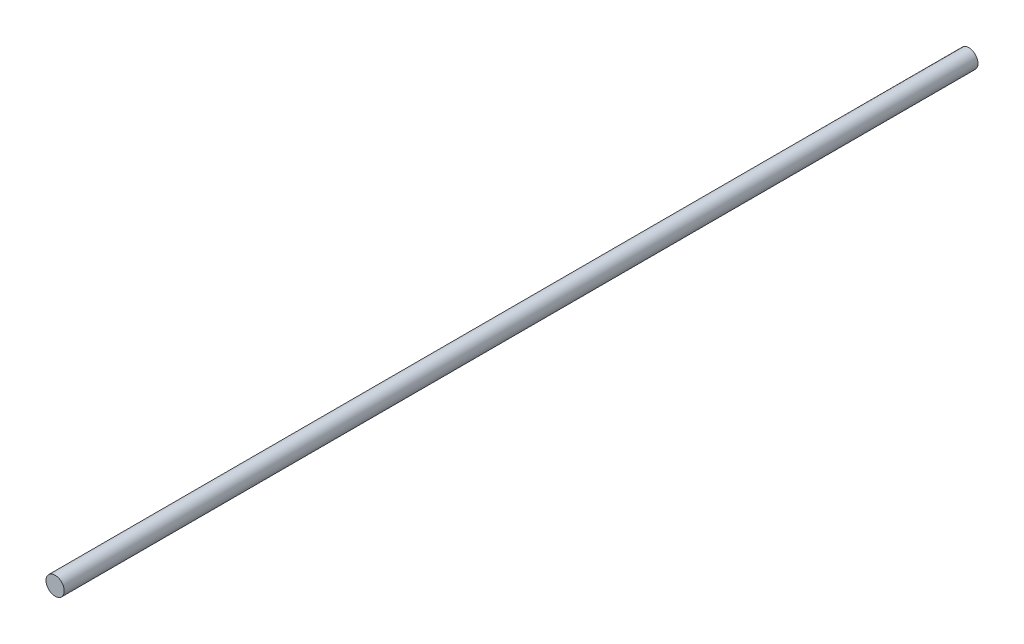
from build123d import *

# Parameters (mm, degrees)
ESQUISSE1_R        = 5
BOSS_EXTRU_1_DEPTH = 500


with BuildPart() as part:
    # Esquisse1 → Boss.-Extru.1 (new body)
    with BuildSketch(Plane.XY):
        Circle(ESQUISSE1_R)
    extrude(amount=BOSS_EXTRU_1_DEPTH)


solid = part.part
